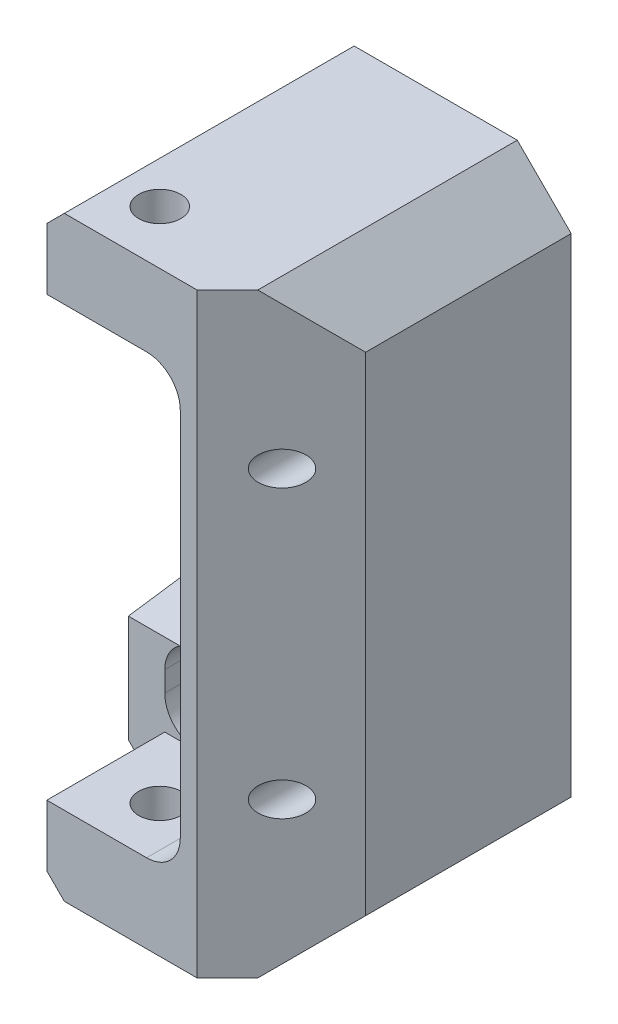
from build123d import *

# Parameters (mm, degrees)
EXTRUDE1_DEPTH                                = 54.61
SKETCH6_R                                     = 3.96875
SKETCH6_W                                     = 6.858
SKETCH6_H                                     = 22.225
CUT_EXTRUDE1_DEPTH                            = 113.268
SKETCH8_W                                     = 6.35
SKETCH8_H                                     = 18.669
CUT_EXTRUDE2_DEPTH                            = 23.225
SKETCH13_R                                    = 23.8125
EXTRUDE4_DEPTH                                = 33.02
FILLET1_R                                     = 6.35
CBORE_FOR_1_4_SOCKET_HEAD_CAP_SCREW1_AT_COUNT = 2
CBORE_FOR_1_4_SOCKET_HEAD_CAP_SCREW1_AT_PITCH = 53.975
CHAMFER4_SIZE                                 = 10.16
CHAMFER7_SIZE                                 = 15.875
F_1_4_0_25_DIAMETER_HOLE1_D                   = 6.35
EXTRUDE9_DEPTH                                = 32.385
EXTRUDE8_DEPTH                                = 17.62


with BuildPart() as part:
    # Sketch5 → Extrude1 (new body)
    with BuildSketch(Plane.XY):
        with BuildLine():
            Line((0, -56.134), (0, 56.134))
            Line((0, 56.134), (-40.894, 56.134))
            Line((-40.894, 56.134), (-51.054, 45.974))
            Line((-51.054, 45.974), (-51.054, 22.606))
            Line((-51.054, 22.606), (-44.196, 22.606))
            Line((-44.196, 22.606), (-44.196, 34.925))
            ThreePointArc((-44.196, 34.925), (-42.336128061, 39.415128061), (-37.846, 41.275))
            Line((-37.846, 41.275), (-25.4, 41.275))
            ThreePointArc((-25.4, 41.275), (-20.909871939, 39.415128061), (-19.05, 34.925))
            Line((-19.05, 34.925), (-19.05, -34.925))
            ThreePointArc((-19.05, -34.925), (-20.909871939, -39.415128061), (-25.4, -41.275))
            Line((-25.4, -41.275), (-37.846, -41.275))
            ThreePointArc((-37.846, -41.275), (-42.336128061, -39.415128061), (-44.196, -34.925))
            Line((-44.196, -34.925), (-44.196, -22.606))
            Line((-44.196, -22.606), (-51.054, -22.606))
            Line((-51.054, -22.606), (-51.054, -45.974))
            Line((-51.054, -45.974), (-40.894, -56.134))
            Line((-40.894, -56.134), (0, -56.134))
        make_face()
    extrude(amount=EXTRUDE1_DEPTH)

    # Sketch6 → Cut-Extrude1 (cut, through all)
    with BuildSketch(Plane.XZ.offset(56.134)):
        with Locations(Location((-33.02, 44.5008, 0), (0, 0, 270))):  # turned: the seam where the file's is
            Circle(SKETCH6_R)
        with Locations((-47.625, 43.4975)):
            Rectangle(SKETCH6_W, SKETCH6_H)
    extrude(amount=-CUT_EXTRUDE1_DEPTH, mode=Mode.SUBTRACT)

    # Sketch8 → Cut-Extrude2 (cut, through all)
    with BuildSketch(Plane.XY.offset(32.385)):
        with Locations((-41.021, -31.9405)):
            Rectangle(SKETCH8_W, SKETCH8_H)
        with BuildLine():
            Line((-44.196, 34.925), (-44.196, 41.275))
            Line((-44.196, 41.275), (-37.846, 41.275))
            ThreePointArc((-37.846, 41.275), (-42.336128061, 39.415128061), (-44.196, 34.925))
        make_face()
    extrude(amount=CUT_EXTRUDE2_DEPTH, mode=Mode.SUBTRACT)

    # Sketch13 → Extrude4 (cut)
    with BuildSketch(Plane(origin=(0, 0, 0), x_dir=(-1, 0, 0), z_dir=(0, 0, -1))):
        with Locations((34.544, 0)):
            Circle(SKETCH13_R)
    extrude(amount=-EXTRUDE4_DEPTH, mode=Mode.SUBTRACT)

    # Fillet1
    fillet1_edges = [part.edges().sort_by_distance(p)[0] for p in [
        (-19.05, -18.082342775, 16.51),
        (-19.05, 18.082342775, 16.51),
    ]]
    fillet(fillet1_edges, radius=FILLET1_R)

    # Sketch18 → CBORE for 1/4 Socket Head Cap Screw1 (revolve, cut)
    with BuildSketch(Plane(origin=(-7.874, 26.9875, 0), x_dir=(0, 1, 0), z_dir=(1, 0, 0))):
        Polygon((0, 0), (0, 21.434665582), (3.96875, 19.05), (3.96875, 2.8448), (3.9878, 2.8448), (3.9878, 0.3683), (4.3561, 0), align=None)
    cbore_for_1_4_socket_head_cap_screw1 = revolve(axis=Axis((-7.874, 26.9875, -6.35), (0, 0, 1)), mode=Mode.SUBTRACT)

    # CBORE for 1/4 Socket Head Cap Screw1 at: CBORE for 1/4 Socket Head Cap Screw1 ×2
    with Locations(*[(0, -i * CBORE_FOR_1_4_SOCKET_HEAD_CAP_SCREW1_AT_PITCH, 0) for i in range(1, CBORE_FOR_1_4_SOCKET_HEAD_CAP_SCREW1_AT_COUNT)]):
        add(cbore_for_1_4_socket_head_cap_screw1, mode=Mode.SUBTRACT)

    # Chamfer4
    chamfer4_edges = [part.edges().sort_by_distance(p)[0] for p in [
        (0, 56.134, 27.305),
        (0, -56.134, 27.305),
    ]]
    chamfer(chamfer4_edges, length=CHAMFER4_SIZE)

    # Chamfer7
    chamfer7_edges = [part.edges().sort_by_distance(p)[0] for p in [
        (0, 0, 54.61),
    ]]
    chamfer(chamfer7_edges, length=CHAMFER7_SIZE)

    # 1/4 (0.25) Diameter Hole1 (through all)
    with Locations(Plane(origin=(0, 0, 0), x_dir=(-1, 0, 0), z_dir=(0, 0, -1))):
        with Locations((7.874, 26.9875), (7.874, -26.9875)):
            Hole(F_1_4_0_25_DIAMETER_HOLE1_D / 2)

    # Sketch22 → Extrude9 (add)
    with BuildSketch(Plane(origin=(0, 0, 0), x_dir=(-1, 0, 0), z_dir=(0, 0, -1))):
        with BuildLine():
            Line((38.354, -24.765), (38.354, -22.606))
            Line((38.354, -22.606), (44.196, -22.606))
            Line((44.196, -22.606), (44.196, -31.094647384))
            ThreePointArc((44.196, -31.094647384), (42.51227796, -26.787867844), (38.354, -24.765))
        make_face()
    extrude9 = extrude(amount=-EXTRUDE9_DEPTH)

    # Mirror3: Extrude9 across plane
    add(extrude9.mirror(Plane.ZX))

    # Sketch17 → Extrude8 (cut)
    with BuildSketch(Plane.ZY.offset(51.054)):
        Polygon((32.385, -25.781), (32.385, -22.606), (10.16, -22.606), align=None)
        Polygon((32.385, 25.781), (32.385, 22.606), (10.16, 22.606), align=None)
    extrude(amount=-EXTRUDE8_DEPTH, mode=Mode.SUBTRACT)


solid = part.part
